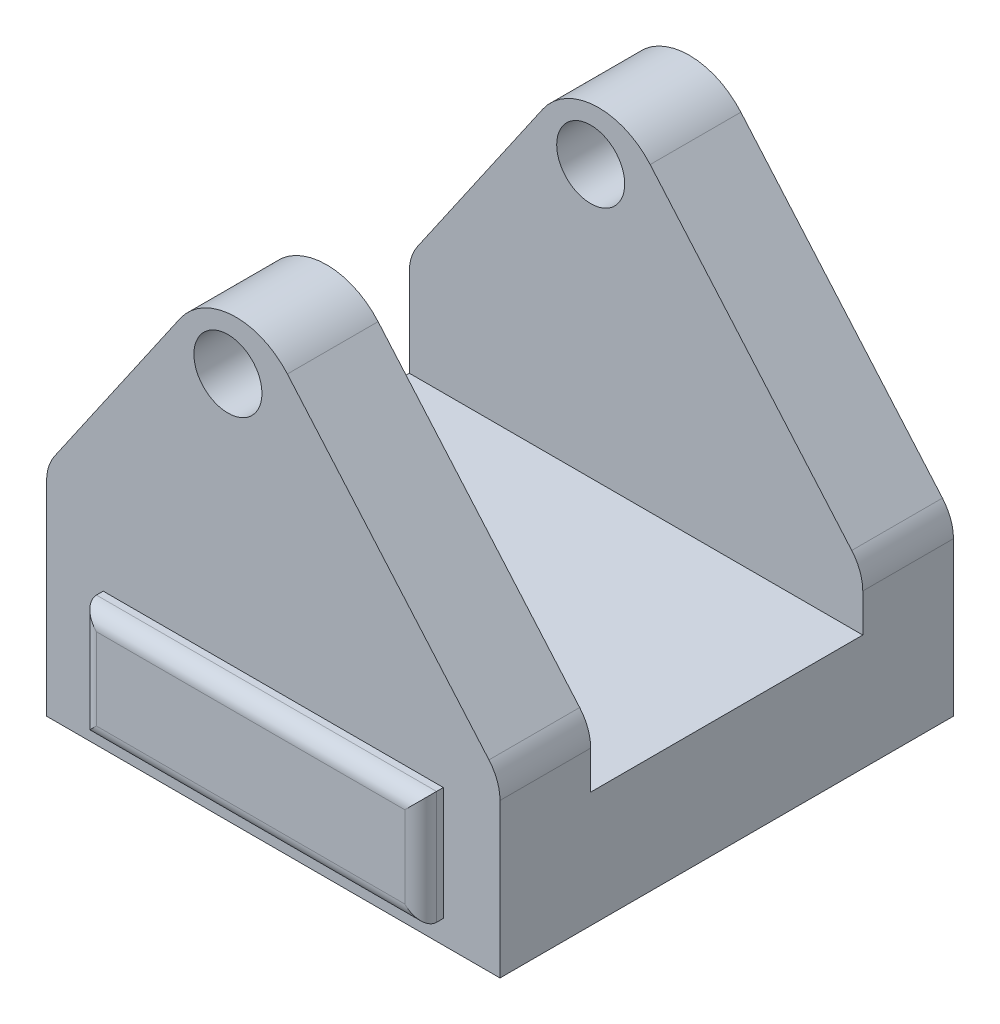
from build123d import *

# Parameters (mm, degrees)
SKETCH1_W               = 200
SKETCH1_H               = 200
BOSS_EXTRUDE1_DEPTH     = 300
SKETCH2_R               = 75
CUT_EXTRUDE1_DEPTH      = 50
CUT_EXTRUDE2_DEPTH      = 201
FILLET1_R               = 30
FILLET2_R               = 20
SKETCH4_W               = 200
SKETCH4_H               = 120
CUT_EXTRUDE3_DEPTH      = 149
SKETCH7_R               = 15
CUT_EXTRUDE4_DEPTH      = 200
CUT_EXTRUDE4_DEPTH_BACK = 149
SKETCH8_W               = 150
SKETCH8_H               = 50
BOSS_EXTRUDE2_DEPTH     = 10
FILLET3_R               = 7
SKETCH9_W               = 150
SKETCH9_H               = 50
BOSS_EXTRUDE3_DEPTH     = 10
FILLET4_R               = 7


with BuildPart() as part:
    # Sketch1 → Boss-Extrude1 (new body)
    with BuildSketch(Plane(origin=(0, 0, 0), x_dir=(1, 0, 0), z_dir=(0, 1, 0))):
        Rectangle(SKETCH1_W, SKETCH1_H)
    extrude(amount=BOSS_EXTRUDE1_DEPTH)

    # Sketch2 → Cut-Extrude1 (cut)
    with BuildSketch(Plane.XZ):
        Circle(SKETCH2_R)
    extrude(amount=-CUT_EXTRUDE1_DEPTH, mode=Mode.SUBTRACT)

    # Sketch3 → Cut-Extrude2 (cut, through all)
    with BuildSketch(Plane.XY.offset(100)):
        Polygon((-100, 95.980685294), (-19.135993401, 213.188644877), (100, 75.250025776), (100, 300), (-100, 300), align=None)
    extrude(amount=-CUT_EXTRUDE2_DEPTH, mode=Mode.SUBTRACT)

    # Fillet1
    fillet1_edges = [part.edges().sort_by_distance(p)[0] for p in [
        (-19.135993401, 213.188644877, 0),
    ]]
    fillet(fillet1_edges, radius=FILLET1_R)

    # Fillet2
    fillet2_edges = [part.edges().sort_by_distance(p)[0] for p in [
        (-100, 95.980685294, 0),
        (100, 75.250025776, 0),
    ]]
    fillet(fillet2_edges, radius=FILLET2_R)

    # Sketch4 → Cut-Extrude3 (cut)
    with BuildSketch(Plane(origin=(0, 200, 0), x_dir=(1, 0, 0), z_dir=(0, 1, 0))):
        Rectangle(SKETCH4_W, SKETCH4_H)
    extrude(amount=-CUT_EXTRUDE3_DEPTH, mode=Mode.SUBTRACT)

    # Sketch7 → Cut-Extrude4 (cut, two sides)
    with BuildSketch(Plane(origin=(0, 0, 60), x_dir=(-1, 0, 0), z_dir=(0, 0, -1))) as cut_extrude4_sk:
        with Locations((20, 170.784862367)):
            Circle(SKETCH7_R)
    extrude(amount=CUT_EXTRUDE4_DEPTH, mode=Mode.SUBTRACT)
    extrude(cut_extrude4_sk.sketch, amount=-CUT_EXTRUDE4_DEPTH_BACK, mode=Mode.SUBTRACT)

    # Sketch8 → Boss-Extrude2 (add)
    with BuildSketch(Plane.XY.offset(100)):
        with Locations((0, 35.260136057)):
            Rectangle(SKETCH8_W, SKETCH8_H)
    extrude(amount=BOSS_EXTRUDE2_DEPTH)

    # Fillet3
    fillet3_edges = [part.edges().sort_by_distance(p)[0] for p in [
        (-75, 35.260136057, 110),
        (0, 10.260136057, 110),
        (75, 35.260136057, 110),
        (0, 60.260136057, 110),
    ]]
    fillet(fillet3_edges, radius=FILLET3_R)

    # Sketch9 → Boss-Extrude3 (add)
    with BuildSketch(Plane(origin=(0, 0, -100), x_dir=(-1, 0, 0), z_dir=(0, 0, -1))):
        with Locations((0, 35.002047413)):
            Rectangle(SKETCH9_W, SKETCH9_H)
    extrude(amount=BOSS_EXTRUDE3_DEPTH)

    # Fillet4
    fillet4_edges = [part.edges().sort_by_distance(p)[0] for p in [
        (75, 35.002047413, -110),
        (0, 10.002047413, -110),
        (-75, 35.002047413, -110),
        (0, 60.002047413, -110),
    ]]
    fillet(fillet4_edges, radius=FILLET4_R)


solid = part.part
